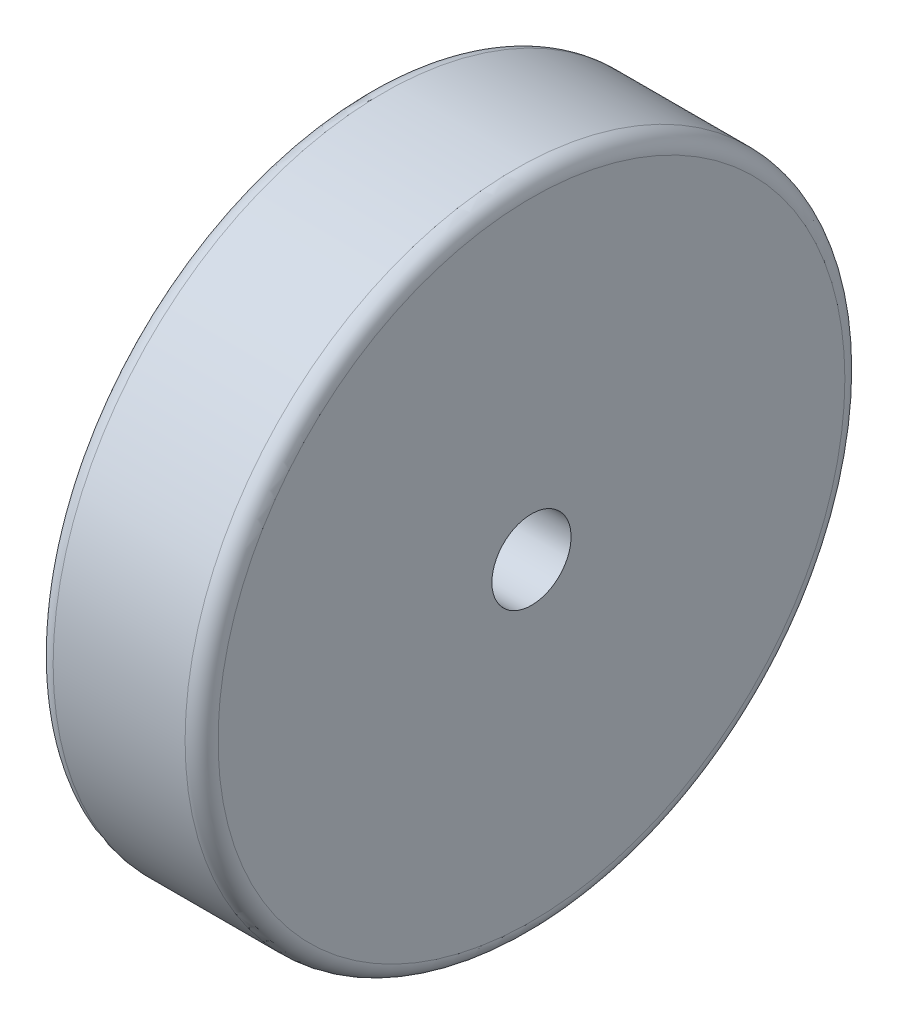
from build123d import *

# Parameters (mm, degrees)
SKETCH2_R           = 50
BOSS_EXTRUDE1_DEPTH = 25
FILLET1_R           = 2.5
SKETCH3_R           = 6
CUT_EXTRUDE1_DEPTH  = 25


with BuildPart() as part:
    # Sketch2 → Boss-Extrude1 (new body)
    with BuildSketch(Plane(origin=(0, 0, 0), x_dir=(0, 0, -1), z_dir=(1, 0, 0))):
        Circle(SKETCH2_R)
    extrude(amount=-BOSS_EXTRUDE1_DEPTH)

    # Fillet1
    fillet1_edges = [part.edges().sort_by_distance(p)[0] for p in [
        (0, 0, 50),
        (-25, 0, 50),
    ]]
    fillet(fillet1_edges, radius=FILLET1_R)

    # Sketch3 → Cut-Extrude1 (cut)
    with BuildSketch(Plane.ZY.offset(25)):
        Circle(SKETCH3_R)
    extrude(amount=-CUT_EXTRUDE1_DEPTH, mode=Mode.SUBTRACT)


solid = part.part
